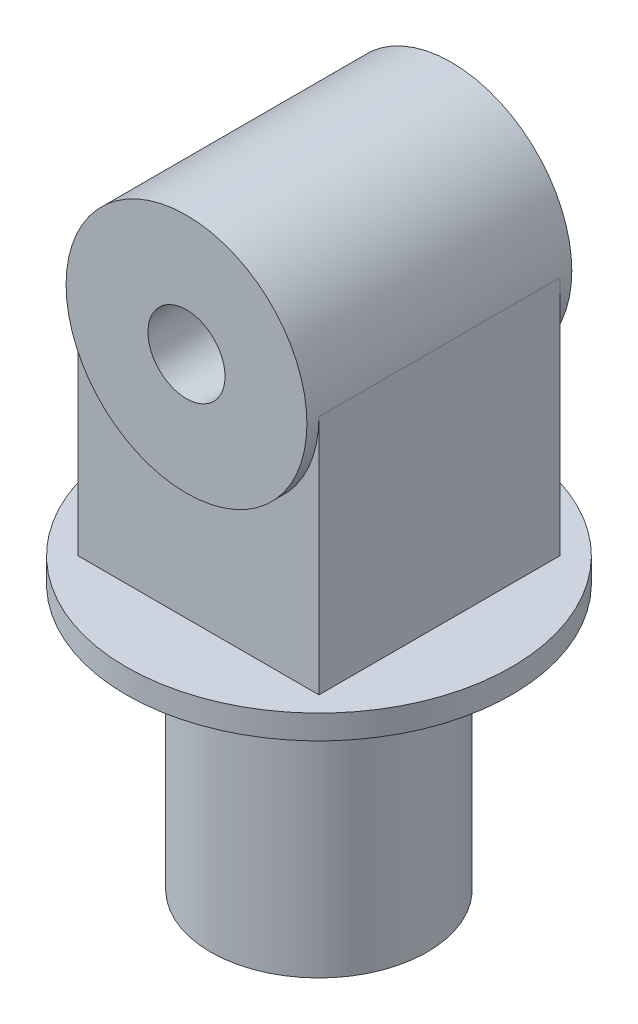
from build123d import *

# Parameters (mm, degrees)
IZIM1_R                     = 22.5
Y_KSEKLIK_EKSTR_ZYON1_DEPTH = 60
IZIM2_R                     = 40
IZIM2_R_2                   = 22.5
Y_KSEKLIK_EKSTR_ZYON2_DEPTH = 5
IZIM3_W                     = 50
IZIM3_H                     = 50
Y_KSEKLIK_EKSTR_ZYON3_DEPTH = 50
IZIM4_R                     = 25
Y_KSEKLIK_EKSTR_ZYON4_DEPTH = 27.5
IZIM5_R                     = 8
KES_EKSTR_ZYON1_DEPTH       = 68.5


with BuildPart() as part:
    # Çizim1 → Yükseklik-Ekstrüzyon1 (new body)
    with BuildSketch(Plane(origin=(0, 0, 0), x_dir=(1, 0, 0), z_dir=(0, 1, 0))):
        Circle(IZIM1_R)
    extrude(amount=Y_KSEKLIK_EKSTR_ZYON1_DEPTH)

    # Çizim2 → Yükseklik-Ekstrüzyon2 (add)
    with BuildSketch(Plane(origin=(0, 60, 0), x_dir=(1, 0, 0), z_dir=(0, 1, 0))):
        Circle(IZIM2_R)
        Circle(IZIM2_R_2, mode=Mode.SUBTRACT)
    extrude(amount=-Y_KSEKLIK_EKSTR_ZYON2_DEPTH)

    # Çizim3 → Yükseklik-Ekstrüzyon3 (add)
    with BuildSketch(Plane(origin=(0, 60, 0), x_dir=(1, 0, 0), z_dir=(0, 1, 0))):
        Rectangle(IZIM3_W, IZIM3_H)
    extrude(amount=Y_KSEKLIK_EKSTR_ZYON3_DEPTH)

    # Çizim4 → Yükseklik-Ekstrüzyon4 (add, symmetric)
    with BuildSketch(Plane.XY):
        with Locations((0, 110)):
            Circle(IZIM4_R)
    extrude(amount=Y_KSEKLIK_EKSTR_ZYON4_DEPTH, both=True)

    # Çizim5 → Kes-Ekstrüzyon1 (cut, through all)
    with BuildSketch(Plane.XY.offset(27.5)):
        with Locations((0, 110)):
            Circle(IZIM5_R)
    extrude(amount=-KES_EKSTR_ZYON1_DEPTH, mode=Mode.SUBTRACT)


solid = part.part
